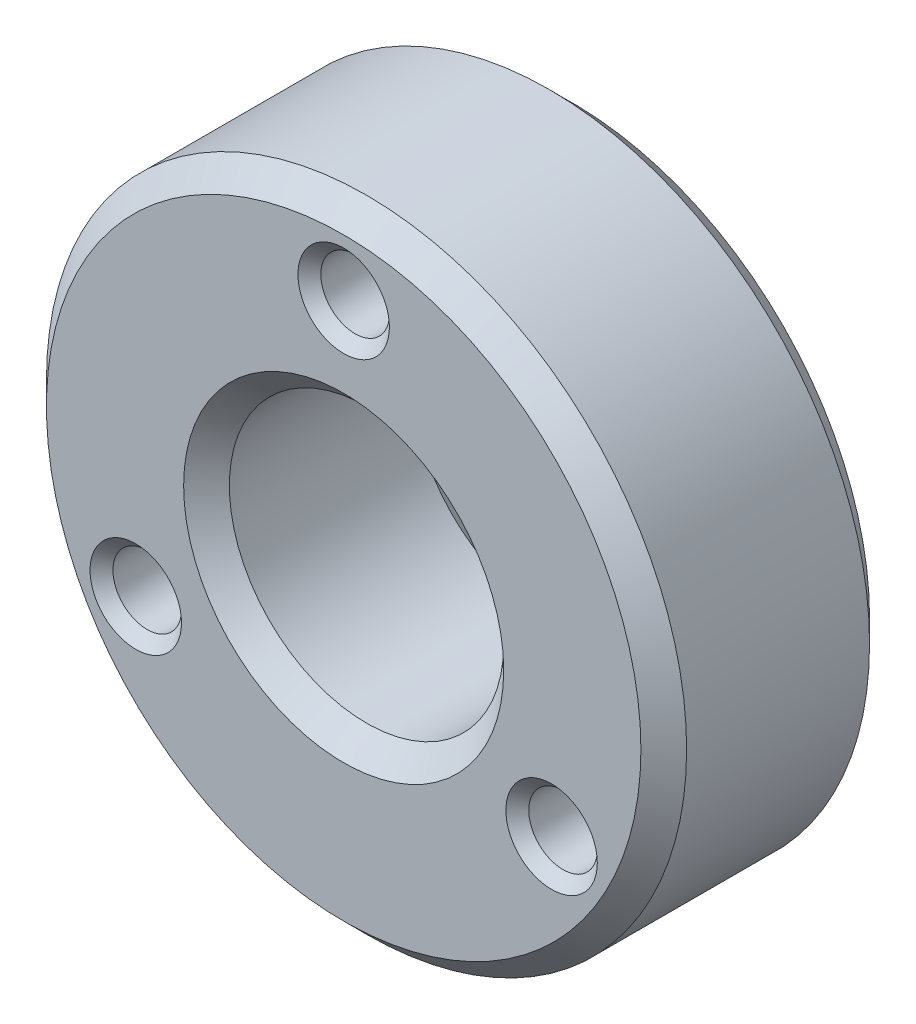
from build123d import *

# Parameters (mm, degrees)
SKETCH1_R           = 14
SKETCH1_R_2         = 6
SKETCH1_R_3         = 1.5
BOSS_EXTRUDE1_DEPTH = 10
CHAMFER1_SIZE       = 1
CHAMFER2_SIZE       = 0.5


with BuildPart() as part:
    # Sketch1 → Boss-Extrude1 (new body)
    with BuildSketch(Plane.XY):
        Circle(SKETCH1_R)
        Circle(SKETCH1_R_2, mode=Mode.SUBTRACT)
        with Locations((0, 10.5)):
            Circle(SKETCH1_R_3, mode=Mode.SUBTRACT)
        with Locations((9.09326674, -5.25)):
            Circle(SKETCH1_R_3, mode=Mode.SUBTRACT)
        with Locations((-9.09326674, -5.25)):
            Circle(SKETCH1_R_3, mode=Mode.SUBTRACT)
    extrude(amount=BOSS_EXTRUDE1_DEPTH)

    # Chamfer1
    chamfer1_edges = [part.edges().sort_by_distance(p)[0] for p in [
        (-14, 0, 0),
        (-14, 0, 10),
        (-6, 0, 0),
        (-6, 0, 10),
    ]]
    chamfer(chamfer1_edges, length=CHAMFER1_SIZE)

    # Chamfer2
    chamfer2_edges = [part.edges().sort_by_distance(p)[0] for p in [
        (7.59326674, -5.25, 0),
        (7.59326674, -5.25, 10),
        (-10.59326674, -5.25, 0),
        (-10.59326674, -5.25, 10),
        (-1.5, 10.5, 0),
        (-1.5, 10.5, 10),
    ]]
    chamfer(chamfer2_edges, length=CHAMFER2_SIZE)


solid = part.part
